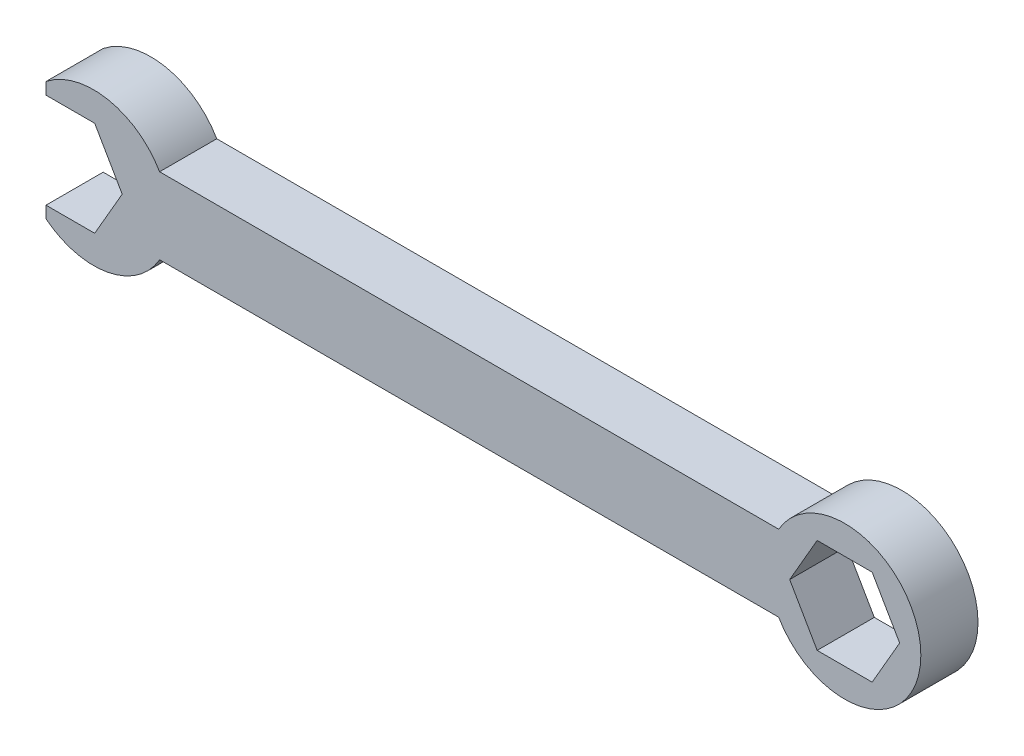
from build123d import *

# Parameters (mm, degrees)
BOSS_EXTRUDE1_DEPTH = 7.62


with BuildPart() as part:
    # Sketch3 → Boss-Extrude1 (new body)
    with BuildSketch(Plane.XY):
        with BuildLine():
            Line((-8.798818102, 5.08), (-91.348818102, 5.08))
            ThreePointArc((-91.348818102, 5.08), (-98.268424141, 9.984696391), (-106.497636205, 7.931147458))
            Line((-106.497636205, 7.931147458), (-106.497636205, 6.35))
            Line((-106.497636205, 6.35), (-100.003810414, 6.35))
            Line((-100.003810414, 6.35), (-96.337636205, 0))
            Line((-96.337636205, 0), (-100.003810414, -6.35))
            Line((-100.003810414, -6.35), (-106.497636205, -6.35))
            Line((-106.497636205, -6.35), (-106.497636205, -7.931147458))
            ThreePointArc((-106.497636205, -7.931147458), (-98.268424141, -9.984696391), (-91.348818102, -5.08))
            Line((-91.348818102, -5.08), (-8.798818102, -5.08))
            ThreePointArc((-8.798818102, -5.08), (10.16, 0), (-8.798818102, 5.08))
        make_face()
        Polygon((7.332348419, 0), (3.666174209, 6.35), (-3.666174209, 6.35), (-7.332348419, 0), (-3.666174209, -6.35), (3.666174209, -6.35), align=None, mode=Mode.SUBTRACT)
    extrude(amount=BOSS_EXTRUDE1_DEPTH)


solid = part.part
